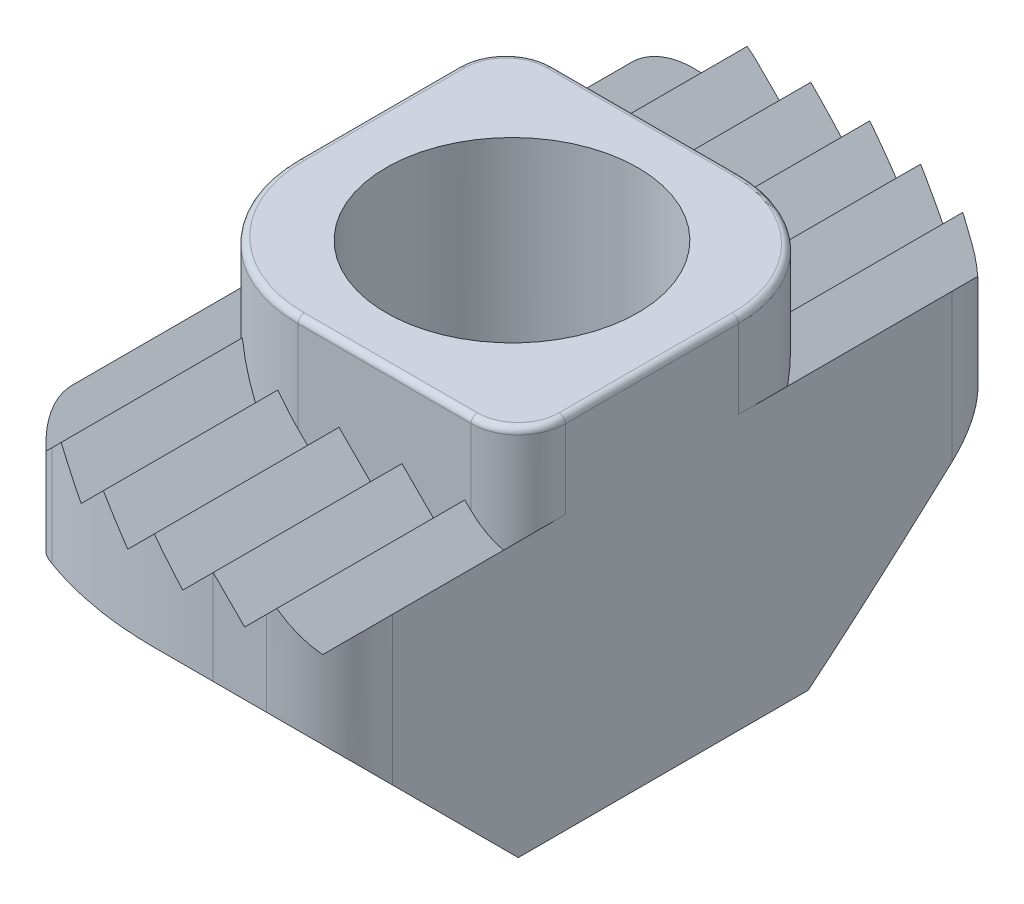
from build123d import *

# Parameters (mm, degrees)
EXTRUDE1_DEPTH          = 4.5
CUT_EXTRUDE1_DEPTH      = 8
CUT_EXTRUDE1_DEPTH_BACK = 8
CUT_EXTRUDE2_DEPTH      = 4
CUT_EXTRUDE2_DEPTH_BACK = 4
CUT_REVOLVE1_ANGLE      = 60
CUT_REVOLVE2_ANGLE      = 60
EXTRUDE2_START          = -0.2
SKETCH7_R               = 2
EXTRUDE2_DEPTH          = 5.5
SKETCH10_R              = 2
CUT_EXTRUDE4_DEPTH      = 11.228025387
FILLET1_R               = 0.1


with BuildPart() as part:
    # Sketch1 → Extrude1 (new body)
    with BuildSketch(Plane(origin=(0, 0, 0), x_dir=(1, 0, 0), z_dir=(0, 1, 0))):
        with BuildLine():
            Line((-1.85, 3.5), (-1, 3.5))
            ThreePointArc((-1, 3.5), (0.66503344, 3.324810774), (2.2571429, 2.806915911))
            ThreePointArc((2.2571429, 2.806915911), (2.688791661, 2.438003962), (2.85, 1.893551439))
            Line((2.85, 1.893551439), (2.85, -1.946775719))
            Line((2.85, -1.946775719), (2.85, -7))
            ThreePointArc((2.85, -7), (2.557106781, -7.707106781), (1.85, -8))
            Line((1.85, -8), (1, -8))
            ThreePointArc((1, -8), (-0.66503344, -7.824810774), (-2.2571429, -7.306915911))
            ThreePointArc((-2.2571429, -7.306915911), (-2.688791661, -6.938003962), (-2.85, -6.393551439))
            Line((-2.85, -6.393551439), (-2.85, -1.946775719))
            Line((-2.85, -1.946775719), (-2.85, 2.5))
            ThreePointArc((-2.85, 2.5), (-2.557106781, 3.207106781), (-1.85, 3.5))
        make_face()
    extrude(amount=EXTRUDE1_DEPTH)

    # Sketch2 → Cut-Extrude1 (cut, two sides: drawn at the far end of the back side and taken through both)
    with BuildSketch(Plane.XY.offset(-CUT_EXTRUDE1_DEPTH_BACK)):
        Polygon((-4, 4.5), (-3.5, 4), (-3, 4.5), (-2.5, 4), (-2, 4.5), (-1.5, 4), (-1, 4.5), (-0.5, 4), (0, 4.5), (0.5, 4), (1, 4.5), (1.5, 4), (2, 4.5), (2.5, 4), (3, 4.5), (3.5, 4), (4, 4.5), (4, 5.5), (-4, 5.5), align=None)
    extrude(amount=CUT_EXTRUDE1_DEPTH + CUT_EXTRUDE1_DEPTH_BACK, mode=Mode.SUBTRACT)

    # Sketch4 → Cut-Extrude2 (cut, two sides: drawn at the far end of the back side and taken through both)
    with BuildSketch(Plane(origin=(0, 0, 0), x_dir=(0, 0, -1), z_dir=(1, 0, 0)).offset(-CUT_EXTRUDE2_DEPTH_BACK)):
        Polygon((4.5, -1), (4.5, 4), (0.5, 0), (-5, 0), (-9, 4), (-9, -1), align=None)
    extrude(amount=CUT_EXTRUDE2_DEPTH + CUT_EXTRUDE2_DEPTH_BACK, mode=Mode.SUBTRACT)

    # Sketch5 → Cut-Revolve1 (revolve, cut)
    with BuildSketch(Plane(origin=(0, 0, 0), x_dir=(0, 0, -1), z_dir=(1, 0, 0))):
        Polygon((0, -1), (-9, -1), (-9, 3), (-8, 3), (-5, 0), (0, 0), align=None)
    revolve(axis=Axis((0, 3, 0), (0, -1, 0)), revolution_arc=CUT_REVOLVE1_ANGLE, mode=Mode.SUBTRACT)

    # Sketch6 → Cut-Revolve2 (revolve, cut)
    with BuildSketch(Plane(origin=(0, 0, 0), x_dir=(0, 0, -1), z_dir=(1, 0, 0))):
        Polygon((4.5, -1), (4.5, 3), (3.5, 3), (0.5, 0), (-4.5, 0), (-4.5, -1), align=None)
    revolve(axis=Axis((0, 3, 4.5), (0, -1, 0)), revolution_arc=CUT_REVOLVE2_ANGLE, mode=Mode.SUBTRACT)

    # Sketch7 → Extrude2 (add)
    with BuildSketch(Plane.XZ.offset(EXTRUDE2_START)):
        with BuildLine():
            Line((2.1, 5), (-0.65, 5))
            ThreePointArc((-0.65, 5), (-2.205634919, 4.355634919), (-2.85, 2.8))
            Line((-2.85, 2.8), (-2.85, 0.25))
            ThreePointArc((-2.85, 0.25), (-2.630330086, -0.280330086), (-2.1, -0.5))
            Line((-2.1, -0.5), (0.85, -0.5))
            ThreePointArc((0.85, -0.5), (2.264213562, 0.085786438), (2.85, 1.5))
            Line((2.85, 1.5), (2.85, 4.25))
            ThreePointArc((2.85, 4.25), (2.630330086, 4.780330086), (2.1, 5))
        make_face()
        with Locations((0, 2.25)):
            Circle(SKETCH7_R, mode=Mode.SUBTRACT)
    extrude(amount=-EXTRUDE2_DEPTH)

    # Sketch10 → Cut-Extrude4 (cut, through all)
    with BuildSketch(Plane(origin=(0, 5.7, 0), x_dir=(1, 0, 0), z_dir=(0, 1, 0))):
        with Locations((0, -2.25)):
            Circle(SKETCH10_R)
    extrude(amount=-CUT_EXTRUDE4_DEPTH, mode=Mode.SUBTRACT)

    # Fillet1
    fillet1_edges = [part.edges().sort_by_distance(p)[0] for p in [
        (-0.625, 5.7, -0.5),
        (-2.630330086, 5.7, -0.280330086),
        (-2.85, 5.7, 1.525),
        (-2.205634919, 5.7, 4.355634919),
        (0.725, 5.7, 5),
        (2.630330086, 5.7, 4.780330086),
        (2.85, 5.7, 2.875),
        (2.264213562, 5.7, 0.085786438),
    ]]
    fillet(fillet1_edges, radius=FILLET1_R)


solid = part.part
